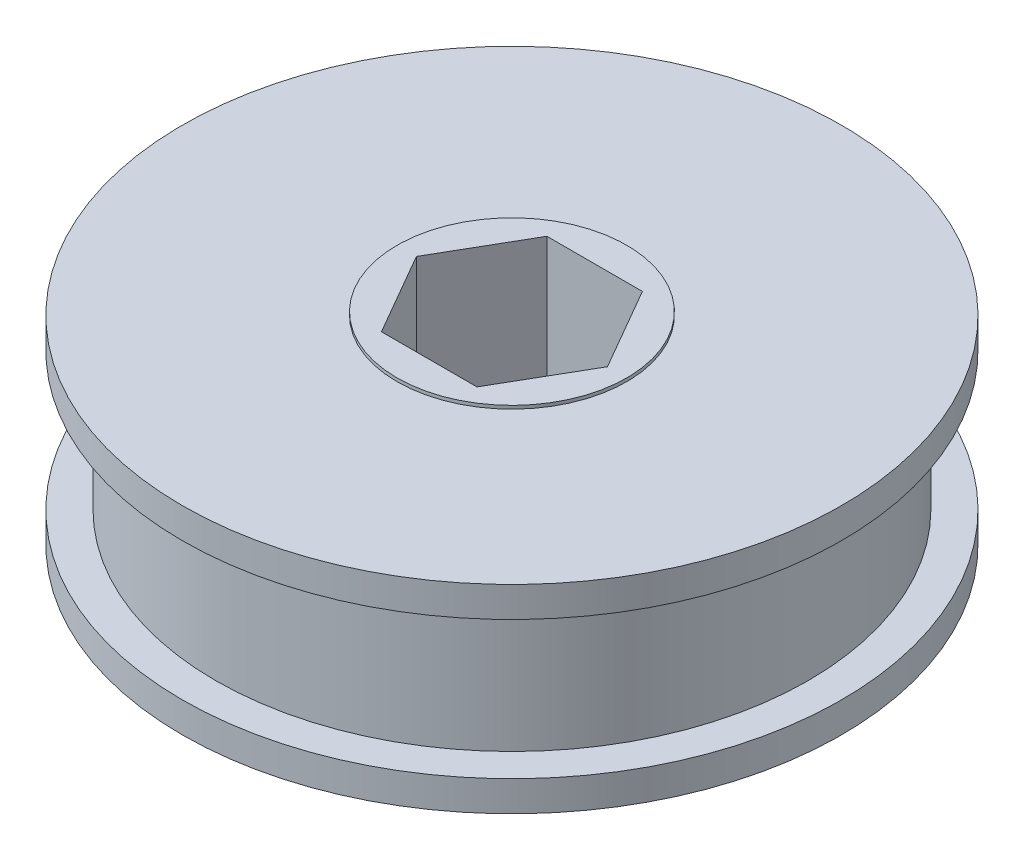
from build123d import *

# Parameters (mm, degrees)
CUT_EXTRUDE1_DEPTH      = 1
CUT_EXTRUDE1_DEPTH_BACK = 16.875


with BuildPart() as part:
    # Sketch2 → Revolve1 (revolve)
    with BuildSketch(Plane(origin=(0, 0, 0), x_dir=(0, 0, -1), z_dir=(1, 0, 0))):
        Polygon((2.54, -3.2131), (8.89, -3.2131), (8.89, -3.4671), (25.5016, -3.4671), (25.5016, -5.8166), (22.9235, -5.8166), (22.9235, -16.4846), (25.5016, -16.4846), (25.5016, -18.8341), (8.89, -18.8341), (8.89, -19.0881), (2.54, -19.0881), align=None)
    revolve(axis=Axis((0, 55, 0), (0, -1, 0)))

    # Sketch3 → Cut-Extrude1 (cut, two sides)
    with BuildSketch(Plane(origin=(0, -3.2131, 0), x_dir=(1, 0, 0), z_dir=(0, 1, 0))) as cut_extrude1_sk:
        Polygon((3.695503603, 6.4008), (-3.695503603, 6.4008), (-7.391007206, 0), (-3.695503603, -6.4008), (3.695503603, -6.4008), (7.391007206, 0), align=None)
    extrude(amount=CUT_EXTRUDE1_DEPTH, mode=Mode.SUBTRACT)
    extrude(cut_extrude1_sk.sketch, amount=-CUT_EXTRUDE1_DEPTH_BACK, mode=Mode.SUBTRACT)


solid = part.part
